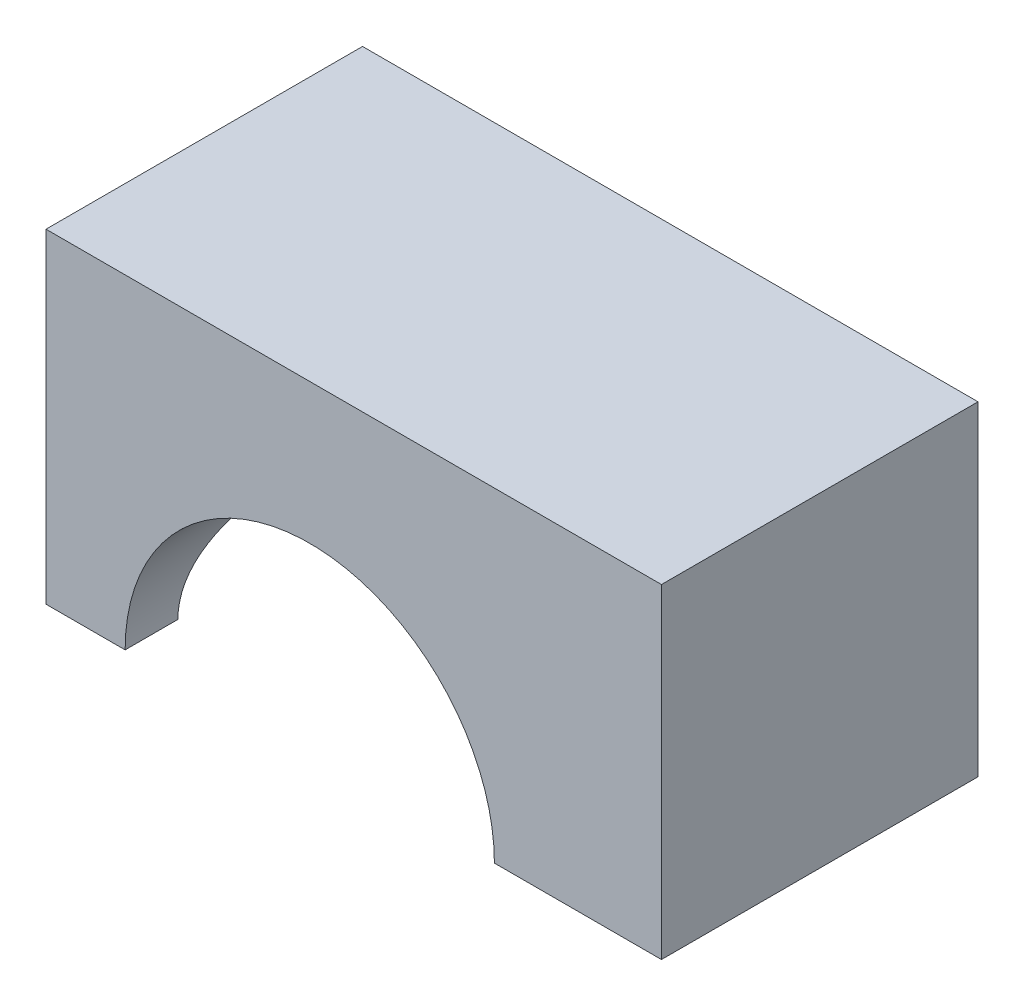
from build123d import *

# Parameters (mm, degrees)
SKETCH1_W           = 40
SKETCH1_H           = 18
BOSS_EXTRUDE1_DEPTH = 18.47
CUT_EXTRUDE1_REACH  = 20
SKETCH2_R           = 10.5
CUT_EXTRUDE3_REACH  = 42
SKETCH4_R           = 6
CUT_EXTRUDE4_REACH  = 20.47
SKETCH5_W           = 5
SKETCH5_H           = 18


with BuildPart() as part:
    # Sketch1 → Boss-Extrude1 (new body)
    with BuildSketch(Plane(origin=(0, 0, 0), x_dir=(1, 0, 0), z_dir=(0, 1, 0))):
        Rectangle(SKETCH1_W, SKETCH1_H)
    extrude(amount=BOSS_EXTRUDE1_DEPTH)

    # Sketch2 → Cut-Extrude1 (cut, up to next)
    with BuildSketch(Plane.XY.offset(9), mode=Mode.PRIVATE) as cut_extrude1_sk1:
        Circle(SKETCH2_R)
    cut_extrude1_tool1 = extrude(cut_extrude1_sk1.sketch, amount=-CUT_EXTRUDE1_REACH, mode=Mode.PRIVATE) & part.part
    add(cut_extrude1_tool1.solids().sort_by_distance((0, 0, 9))[0], mode=Mode.SUBTRACT)

    # Sketch4 → Cut-Extrude3 (cut, up to next)
    with BuildSketch(Plane.ZY.offset(20), mode=Mode.PRIVATE) as cut_extrude3_sk1:
        Circle(SKETCH4_R)
    cut_extrude3_tool1 = extrude(cut_extrude3_sk1.sketch, amount=-CUT_EXTRUDE3_REACH, mode=Mode.PRIVATE) & part.part
    add(cut_extrude3_tool1.solids().sort_by_distance((-20, 0, 0))[0], mode=Mode.SUBTRACT)

    # Sketch5 → Cut-Extrude4 (cut, up to next)
    with BuildSketch(Plane.XZ, mode=Mode.PRIVATE) as cut_extrude4_sk1:
        with Locations((-17.5, 0)):
            Rectangle(SKETCH5_W, SKETCH5_H)
    cut_extrude4_tool1 = extrude(cut_extrude4_sk1.sketch, amount=-CUT_EXTRUDE4_REACH, mode=Mode.PRIVATE) & part.part
    add(cut_extrude4_tool1.solids().sort_by_distance((-17.5, 0, 0))[0], mode=Mode.SUBTRACT)


solid = part.part
